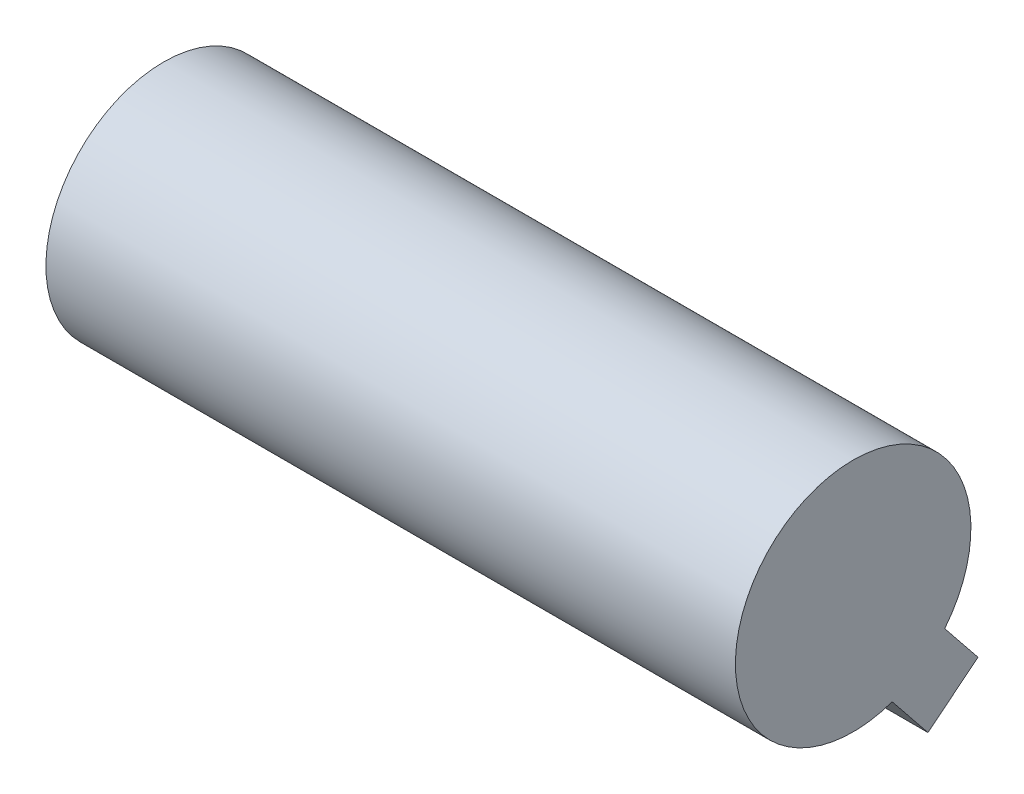
from build123d import *

# Parameters (mm, degrees)
SKETCH1_R             = 7
BOSS_EXTRUDE1_DEPTH   = 40.99
SKETCH2_W             = 14.337226175
SKETCH2_H             = 3.81556612
BOSS_EXTRUDE2_DEPTH   = 3
SKETCH2_W_2           = 14.616397067
BOSS_EXTRUDE2_2_DEPTH = 3
SKETCH3_W             = 14.616397067
SKETCH3_H             = 3.81556612
SKETCH3_W_2           = 14.337226175
BOSS_EXTRUDE3_DEPTH   = 10


with BuildPart() as part:
    # Sketch1 → Boss-Extrude1 (new body)
    with BuildSketch(Plane(origin=(0, 0, 0), x_dir=(0, 0, -1), z_dir=(1, 0, 0))):
        Circle(SKETCH1_R)
    extrude(amount=BOSS_EXTRUDE1_DEPTH)



with BuildPart() as body_2:
    # Sketch2 → Boss-Extrude2 (new body)
    with BuildSketch(Plane(origin=(0, -5.457447914, -4.383635737), x_dir=(1, 0, 0), z_dir=(0, -0.779635416, -0.626233677))):
        with Locations((7.168613088, 0.421848142)):
            Rectangle(SKETCH2_W, SKETCH2_H)
    extrude(amount=BOSS_EXTRUDE2_DEPTH)


with BuildPart() as body_3:
    # Sketch2 → Boss-Extrude2 2 (new body)
    with BuildSketch(Plane(origin=(0, -5.457447914, -4.383635737), x_dir=(1, 0, 0), z_dir=(0, -0.779635416, -0.626233677))):
        with Locations((33.681801467, 0.421848142)):
            Rectangle(SKETCH2_W_2, SKETCH2_H)
    extrude(amount=BOSS_EXTRUDE2_2_DEPTH)


with BuildPart() as part_1:
    add(part.part)

    add(body_2.part)  # Boss-Extrude3 merges body 2

    add(body_3.part)  # Boss-Extrude3 merges body 3
    # Sketch3 → Boss-Extrude3 (add)
    with BuildSketch(Plane(origin=(0, -5.457447914, -4.383635737), x_dir=(1, 0, 0), z_dir=(0, 0.779635416, 0.626233677))):
        with Locations((33.681801467, -0.421848142)):
            Rectangle(SKETCH3_W, SKETCH3_H)
        with Locations((7.168613088, -0.421848142)):
            Rectangle(SKETCH3_W_2, SKETCH3_H)
    extrude(amount=BOSS_EXTRUDE3_DEPTH)


solid = part_1.part
